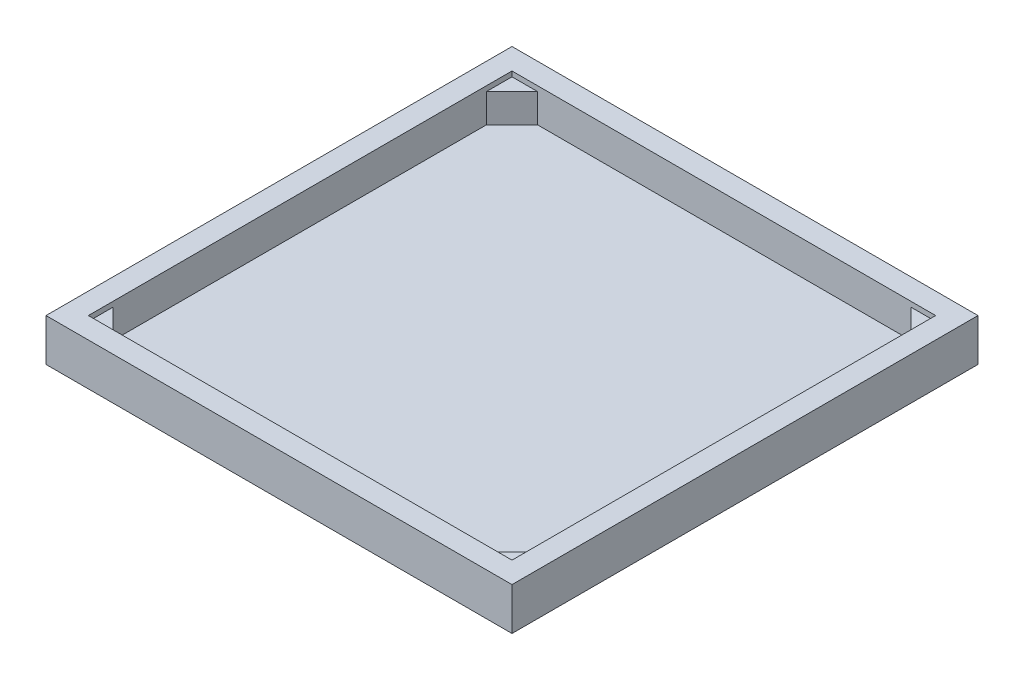
from build123d import *

# Parameters (mm, degrees)
SKETCH1_W           = 550
SKETCH1_H           = 550
BOSS_EXTRUDE1_DEPTH = 50
SKETCH2_W           = 500
SKETCH2_H           = 500
CUT_EXTRUDE1_DEPTH  = 40
BOSS_EXTRUDE2_DEPTH = 34
CIRPATTERN1_COUNT   = 4


with BuildPart() as part:
    # Sketch1 → Boss-Extrude1 (new body)
    with BuildSketch(Plane(origin=(0, 0, 0), x_dir=(1, 0, 0), z_dir=(0, 1, 0))):
        Rectangle(SKETCH1_W, SKETCH1_H)
    extrude(amount=BOSS_EXTRUDE1_DEPTH)

    # Sketch2 → Cut-Extrude1 (cut)
    with BuildSketch(Plane(origin=(0, 50, 0), x_dir=(1, 0, 0), z_dir=(0, 1, 0))):
        Rectangle(SKETCH2_W, SKETCH2_H)
    extrude(amount=-CUT_EXTRUDE1_DEPTH, mode=Mode.SUBTRACT)

    # Sketch3 → Boss-Extrude2 (add)
    with BuildSketch(Plane(origin=(0, 10, 0), x_dir=(1, 0, 0), z_dir=(0, 1, 0))):
        Polygon((-250, 250), (-220, 250), (-250, 220), align=None)
    boss_extrude2 = extrude(amount=BOSS_EXTRUDE2_DEPTH)

    # CirPattern1: Boss-Extrude2 ×4 about axis
    cirpattern1_axis = Axis((0.432779002, 0, 0.432779002), (0, 1, 0))
    for i in range(1, CIRPATTERN1_COUNT):
        add(boss_extrude2.rotate(cirpattern1_axis, i * 360 / CIRPATTERN1_COUNT))


solid = part.part
